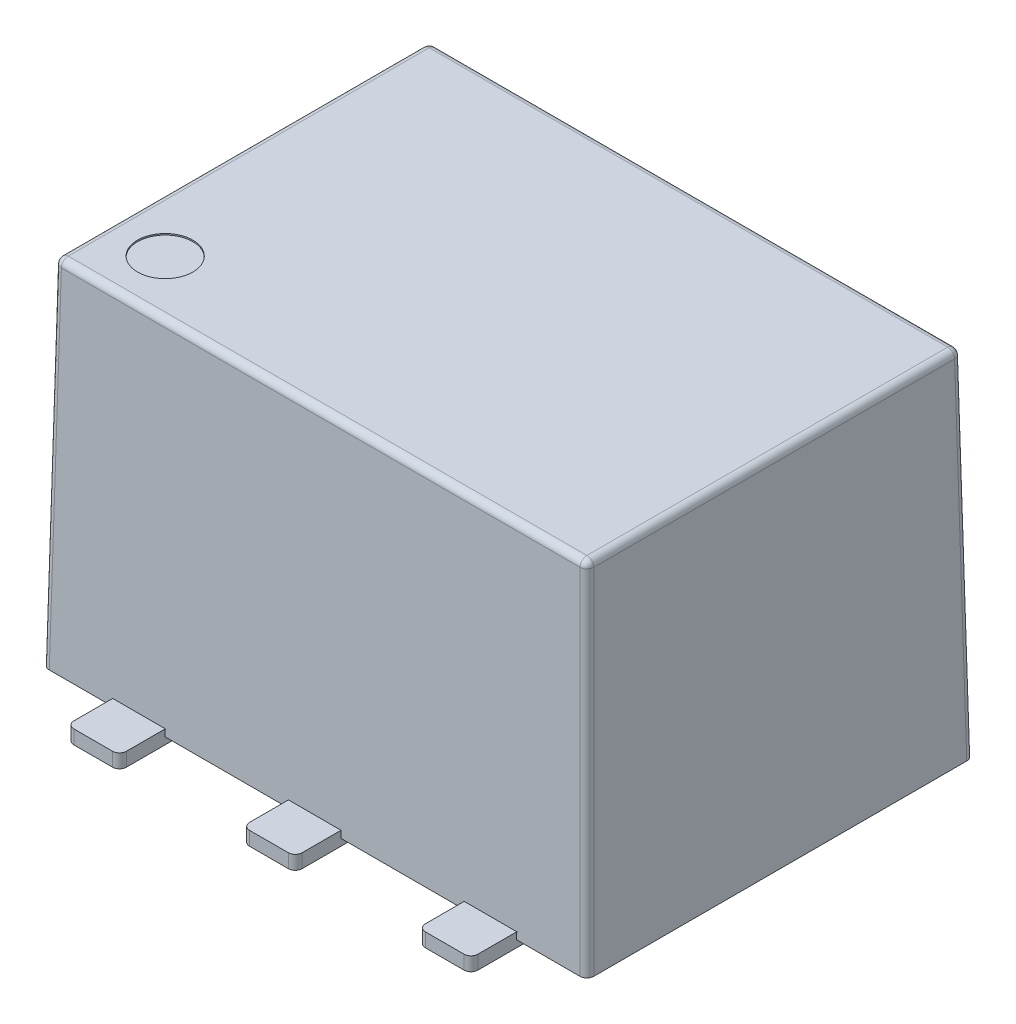
from build123d import *

# Parameters (mm, degrees)
SKETCH1_W           = 7.87
SKETCH1_H           = 5.59
BOSS_EXTRUDE1_DEPTH = 5.13
BOSS_EXTRUDE1_TAPER = 1
SKETCH2_W           = 0.76
SKETCH2_H           = 1.16
BOSS_EXTRUDE2_DEPTH = 0.1
FILLET1_R           = 0.1
SKETCH3_R           = 0.4
CUT_EXTRUDE1_DEPTH  = 0.02


with BuildPart() as part:
    # Sketch1 → Boss-Extrude1 (new body)
    with BuildSketch(Plane(origin=(0, 0, 0), x_dir=(1, 0, 0), z_dir=(0, 1, 0))):
        Rectangle(SKETCH1_W, SKETCH1_H)
    extrude(amount=BOSS_EXTRUDE1_DEPTH, taper=BOSS_EXTRUDE1_TAPER)

    # Sketch2 → Boss-Extrude2 (add, symmetric)
    with BuildSketch(Plane.XZ):
        with Locations((0, 2.875)):
            Rectangle(SKETCH2_W, SKETCH2_H)
        with Locations((2.54, 2.875)):
            Rectangle(SKETCH2_W, SKETCH2_H)
        with Locations((-2.54, 2.875)):
            Rectangle(SKETCH2_W, SKETCH2_H)
        with Locations((-2.54, -2.875)):
            Rectangle(SKETCH2_W, SKETCH2_H)
        with Locations((0, -2.875)):
            Rectangle(SKETCH2_W, SKETCH2_H)
        with Locations((2.54, -2.875)):
            Rectangle(SKETCH2_W, SKETCH2_H)
    extrude(amount=BOSS_EXTRUDE2_DEPTH, both=True)

    # Fillet1
    fillet1_edges = [part.edges().sort_by_distance(p)[0] for p in [
        (2.92, 0, -3.455),
        (2.16, 0, -3.455),
        (-3.845455517, 5.13, 0),
        (0, 5.13, 2.705455517),
        (-0.38, 0, 3.455),
        (0.38, 0, 3.455),
        (-2.92, 0, 3.455),
        (-2.16, 0, 3.455),
        (3.845455517, 5.13, 0),
        (2.16, 0, 3.455),
        (2.92, 0, 3.455),
        (-2.16, 0, -3.455),
        (-2.92, 0, -3.455),
        (3.890227758, 2.565, 2.750227758),
        (-3.890227758, 2.565, 2.750227758),
        (-3.890227758, 2.565, -2.750227758),
        (3.890227758, 2.565, -2.750227758),
        (0.38, 0, -3.455),
        (-0.38, 0, -3.455),
        (0, 5.13, -2.705455517),
    ]]
    fillet(fillet1_edges, radius=FILLET1_R)

    # Sketch3 → Cut-Extrude1 (cut)
    with BuildSketch(Plane(origin=(0, 5.13, 0), x_dir=(1, 0, 0), z_dir=(0, 1, 0))):
        with Locations((-3.047185791, -1.907185791)):
            Circle(SKETCH3_R)
    extrude(amount=-CUT_EXTRUDE1_DEPTH, mode=Mode.SUBTRACT)


solid = part.part
